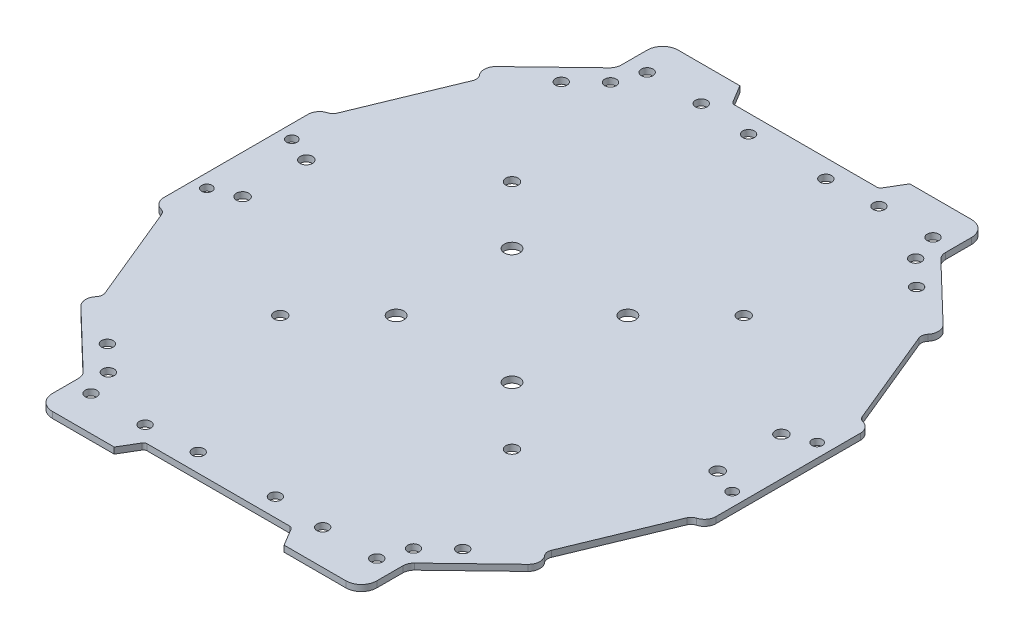
from build123d import *

# Parameters (mm, degrees)
SKETCH1_R        = 1.5
SKETCH1_R_2      = 1.600010398
SKETCH1_R_3      = 1.6
SKETCH1_R_4      = 2
SKETCH1_R_5      = 1.35
EXTRUSION1_DEPTH = 1.6
FILLET1_R        = 1
FILLET2_R        = 4
FILLET3_R        = 3
FILLET4_R        = 3
FILLET5_R        = 2
FILLET6_R        = 2
FILLET7_R        = 3
FILLET8_R        = 3
FILLET9_R        = 2
FILLET10_R       = 2
FILLET11_R       = 3


with BuildPart() as part:
    # Sketch1 → Extrusion1 (new body)
    with BuildSketch(Plane(origin=(0, 0, 0), x_dir=(-1, 0, 0), z_dir=(0, 1, 0))):
        Polygon((59.775158519, 259.059874387), (56.775158519, 264.05987395), (36.775158519, 264.05987395), (36.775158519, 252.05987395), (18.755330752, 234.731117294), (21.527931817, 231.847944851), (10.275158581, 204.559863083), (7.275158519, 204.559863083), (7.275158519, 183.059873956), (7.275158519, 161.559884829), (10.275158581, 161.559884829), (21.527931817, 134.27180306), (18.755330752, 131.388630617), (36.775158519, 114.059873961), (36.775158519, 102.059873961), (56.775158519, 102.059873961), (59.775158519, 107.059873524), (78.775158519, 107.059873524), (97.775158519, 107.059873524), (100.775158519, 102.059873961), (120.775158519, 102.059873961), (120.775158519, 114.059873961), (138.794986286, 131.388630617), (136.022385221, 134.27180306), (147.275158457, 161.559884829), (150.275158519, 161.559884829), (150.275158519, 183.059873956), (150.275158519, 204.559863083), (147.275158457, 204.559863083), (136.022385221, 231.847944851), (138.794986286, 234.731117294), (120.775158519, 252.05987395), (120.775158519, 264.05987395), (100.775158519, 264.05987395), (97.775158519, 259.059874387), (78.775158519, 259.059874387), align=None)
        with Locations((55.775158457, 111.059872631)):
            Circle(SKETCH1_R, mode=Mode.SUBTRACT)
        with Locations((39.275158457, 118.059884829)):
            Circle(SKETCH1_R, mode=Mode.SUBTRACT)
        with Locations((48.775158519, 213.059873956)):
            Circle(SKETCH1_R_2, mode=Mode.SUBTRACT)
        with Locations((48.775158519, 153.059873956)):
            Circle(SKETCH1_R_2, mode=Mode.SUBTRACT)
        with Locations((17.275158457, 174.809872631)):
            Circle(SKETCH1_R_3, mode=Mode.SUBTRACT)
        with Locations((108.775158519, 153.059873956)):
            Circle(SKETCH1_R_2, mode=Mode.SUBTRACT)
        with Locations((93.775158519, 198.059873956)):
            Circle(SKETCH1_R_4, mode=Mode.SUBTRACT)
        with Locations((63.775158519, 198.059873956)):
            Circle(SKETCH1_R_4, mode=Mode.SUBTRACT)
        with Locations((63.775158519, 168.059873956)):
            Circle(SKETCH1_R_4, mode=Mode.SUBTRACT)
        with Locations((93.775158519, 168.059873956)):
            Circle(SKETCH1_R_4, mode=Mode.SUBTRACT)
        with Locations((41.775158457, 255.059863083)):
            Circle(SKETCH1_R, mode=Mode.SUBTRACT)
        with Locations((39.275158457, 248.059863083)):
            Circle(SKETCH1_R, mode=Mode.SUBTRACT)
        with Locations((10.775158457, 194.05987528)):
            Circle(SKETCH1_R_5, mode=Mode.SUBTRACT)
        with Locations((88.775158581, 111.809884829)):
            Circle(SKETCH1_R, mode=Mode.SUBTRACT)
        with Locations((115.775158581, 111.059884829)):
            Circle(SKETCH1_R, mode=Mode.SUBTRACT)
        with Locations((118.275158581, 118.059884829)):
            Circle(SKETCH1_R, mode=Mode.SUBTRACT)
        with Locations((140.275158581, 174.809872631)):
            Circle(SKETCH1_R_3, mode=Mode.SUBTRACT)
        with Locations((115.775158581, 255.059863083)):
            Circle(SKETCH1_R, mode=Mode.SUBTRACT)
        with Locations((88.775158581, 254.309863083)):
            Circle(SKETCH1_R, mode=Mode.SUBTRACT)
        with Locations((140.275158581, 191.30987528)):
            Circle(SKETCH1_R_3, mode=Mode.SUBTRACT)
        with Locations((146.775158581, 194.05987528)):
            Circle(SKETCH1_R_5, mode=Mode.SUBTRACT)
        with Locations((101.775158581, 255.05987528)):
            Circle(SKETCH1_R, mode=Mode.SUBTRACT)
        with Locations((118.275158581, 248.059863083)):
            Circle(SKETCH1_R, mode=Mode.SUBTRACT)
        with Locations((146.775158581, 172.059872631)):
            Circle(SKETCH1_R_5, mode=Mode.SUBTRACT)
        with Locations((101.775158581, 111.059872631)):
            Circle(SKETCH1_R, mode=Mode.SUBTRACT)
        with Locations((17.275158457, 191.30987528)):
            Circle(SKETCH1_R_3, mode=Mode.SUBTRACT)
        with Locations((55.775158457, 255.05987528)):
            Circle(SKETCH1_R, mode=Mode.SUBTRACT)
        with Locations((68.775158457, 254.309863083)):
            Circle(SKETCH1_R, mode=Mode.SUBTRACT)
        with Locations((10.775158457, 172.059872631)):
            Circle(SKETCH1_R_5, mode=Mode.SUBTRACT)
        with Locations((68.775158457, 111.809884829)):
            Circle(SKETCH1_R, mode=Mode.SUBTRACT)
        with Locations((41.775158457, 111.059884829)):
            Circle(SKETCH1_R, mode=Mode.SUBTRACT)
        with Locations((32.775158457, 124.309884829)):
            Circle(SKETCH1_R, mode=Mode.SUBTRACT)
        with Locations((124.775158581, 241.809863083)):
            Circle(SKETCH1_R, mode=Mode.SUBTRACT)
        with Locations((32.775158457, 241.809863083)):
            Circle(SKETCH1_R, mode=Mode.SUBTRACT)
        with Locations((108.775158519, 213.059873956)):
            Circle(SKETCH1_R_2, mode=Mode.SUBTRACT)
        with Locations((124.775158581, 124.309884829)):
            Circle(SKETCH1_R, mode=Mode.SUBTRACT)
    extrude(amount=EXTRUSION1_DEPTH)

    # Fillet1
    fillet1_edges = [part.edges().sort_by_distance(p)[0] for p in [
        (-97.775158519, 0.8, 259.059874387),
        (-97.775158519, 0.8, 107.059873524),
        (-59.775158519, 0.8, 107.059873524),
        (-59.775158519, 0.8, 259.059874387),
    ]]
    fillet(fillet1_edges, radius=FILLET1_R)

    # Fillet2
    fillet2_edges = [part.edges().sort_by_distance(p)[0] for p in [
        (-120.775158519, 0.8, 264.05987395),
        (-120.775158519, 0.8, 102.059873961),
        (-36.775158519, 0.8, 102.059873961),
        (-36.775158519, 0.8, 264.05987395),
    ]]
    fillet(fillet2_edges, radius=FILLET2_R)

    # Fillet3
    fillet3_edges = [part.edges().sort_by_distance(p)[0] for p in [
        (-120.775158519, 0.8, 252.05987395),
        (-120.775158519, 0.8, 114.059873961),
        (-36.775158519, 0.8, 114.059873961),
        (-36.775158519, 0.8, 252.05987395),
    ]]
    fillet(fillet3_edges, radius=FILLET3_R)

    # Fillet4
    fillet4_edges = [part.edges().sort_by_distance(p)[0] for p in [
        (-138.794986286, 0.8, 234.731117294),
    ]]
    fillet(fillet4_edges, radius=FILLET4_R)

    # Fillet5
    fillet5_edges = [part.edges().sort_by_distance(p)[0] for p in [
        (-136.022385221, 0.8, 231.847944851),
    ]]
    fillet(fillet5_edges, radius=FILLET5_R)

    # Fillet6
    fillet6_edges = [part.edges().sort_by_distance(p)[0] for p in [
        (-21.527931817, 0.8, 231.847944851),
    ]]
    fillet(fillet6_edges, radius=FILLET6_R)

    # Fillet7
    fillet7_edges = [part.edges().sort_by_distance(p)[0] for p in [
        (-18.755330752, 0.8, 234.731117294),
    ]]
    fillet(fillet7_edges, radius=FILLET7_R)

    # Fillet8
    fillet8_edges = [part.edges().sort_by_distance(p)[0] for p in [
        (-138.794986286, 0.8, 131.388630617),
        (-18.755330752, 0.8, 131.388630617),
    ]]
    fillet(fillet8_edges, radius=FILLET8_R)

    # Fillet9
    fillet9_edges = [part.edges().sort_by_distance(p)[0] for p in [
        (-21.527931817, 0.8, 134.27180306),
        (-136.022385221, 0.8, 134.27180306),
    ]]
    fillet(fillet9_edges, radius=FILLET9_R)

    # Fillet10
    fillet10_edges = [part.edges().sort_by_distance(p)[0] for p in [
        (-147.275158457, 0.8, 204.559863083),
        (-147.275158457, 0.8, 161.559884829),
        (-10.275158581, 0.8, 161.559884829),
        (-10.275158581, 0.8, 204.559863083),
    ]]
    fillet(fillet10_edges, radius=FILLET10_R)

    # Fillet11
    fillet11_edges = [part.edges().sort_by_distance(p)[0] for p in [
        (-150.275158519, 0.8, 161.559884829),
        (-150.275158519, 0.8, 204.559863083),
        (-7.275158519, 0.8, 204.559863083),
        (-7.275158519, 0.8, 161.559884829),
    ]]
    fillet(fillet11_edges, radius=FILLET11_R)


solid = part.part
